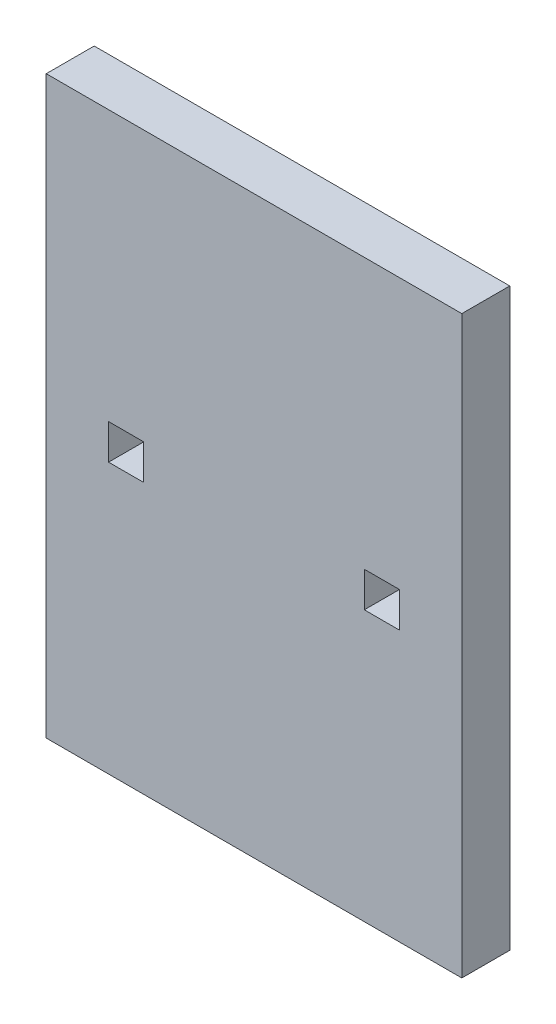
from build123d import *

# Parameters (mm, degrees)
IZIM1_W                     = 260
IZIM1_H                     = 360
IZIM1_W_2                   = 22
IZIM1_H_2                   = 22
Y_KSEKLIK_EKSTR_ZYON1_DEPTH = 30


with BuildPart() as part:
    # Çizim1 → Yükseklik-Ekstrüzyon1 (new body)
    with BuildSketch(Plane.XY):
        with Locations((130, -180)):
            Rectangle(IZIM1_W, IZIM1_H)
        with Locations((50, -180)):
            Rectangle(IZIM1_W_2, IZIM1_H_2, mode=Mode.SUBTRACT)
        with Locations((210, -180)):
            Rectangle(IZIM1_W_2, IZIM1_H_2, mode=Mode.SUBTRACT)
    extrude(amount=Y_KSEKLIK_EKSTR_ZYON1_DEPTH)


solid = part.part
